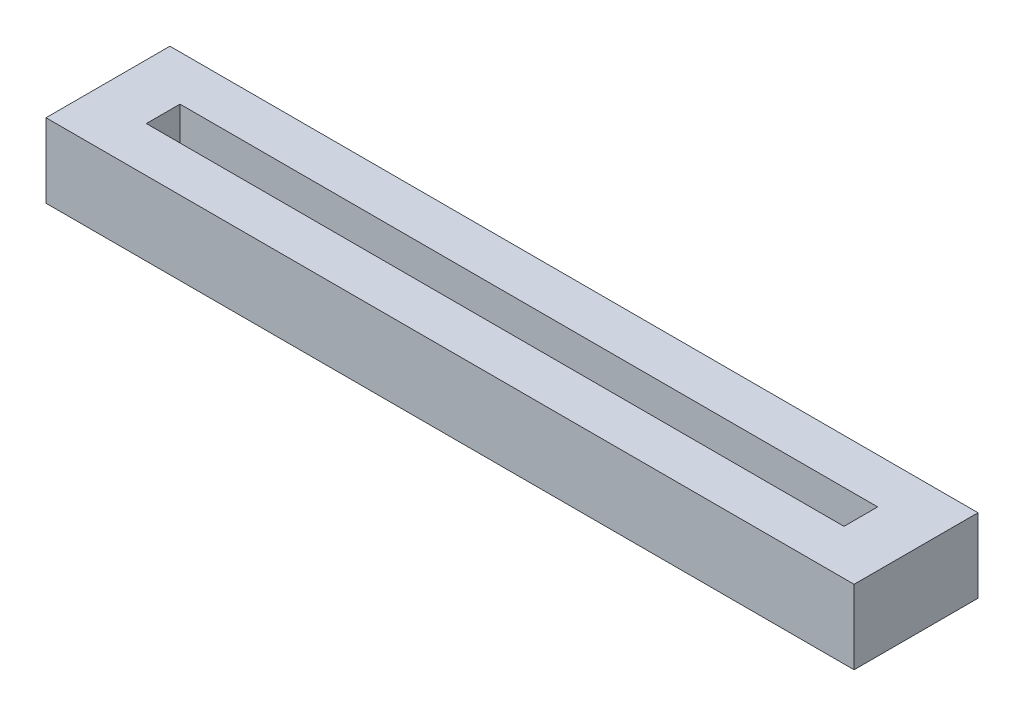
from build123d import *

# Parameters (mm, degrees)
SKETCH1_W           = 60
SKETCH1_H           = 9.2
BOSS_EXTRUDE1_DEPTH = 5.5
SKETCH2_W           = 51.8
SKETCH2_H           = 2.5
CUT_EXTRUDE1_DEPTH  = 4.7


with BuildPart() as part:
    # Sketch1 → Boss-Extrude1 (new body)
    with BuildSketch(Plane(origin=(0, 0, 0), x_dir=(1, 0, 0), z_dir=(0, 1, 0))):
        Rectangle(SKETCH1_W, SKETCH1_H)
    extrude(amount=BOSS_EXTRUDE1_DEPTH)

    # Sketch2 → Cut-Extrude1 (cut)
    with BuildSketch(Plane(origin=(0, 5.5, 0), x_dir=(1, 0, 0), z_dir=(0, 1, 0))):
        Rectangle(SKETCH2_W, SKETCH2_H)
    extrude(amount=-CUT_EXTRUDE1_DEPTH, mode=Mode.SUBTRACT)


solid = part.part
